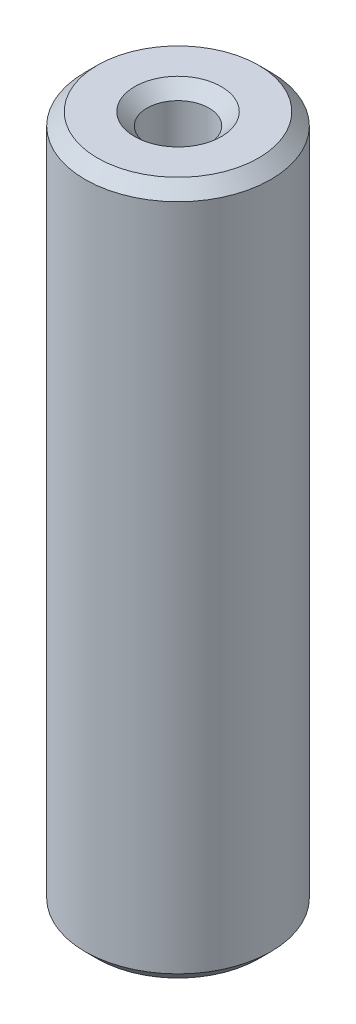
from build123d import *

# Parameters (mm, degrees)
ESQUISSE1_R      = 7.5
ESQUISSE1_R_2    = 2.5
EXTRUSION1_DEPTH = 56
CHANFREIN1_SIZE  = 1


with BuildPart() as part:
    # Esquisse1 → Extrusion1 (new body)
    with BuildSketch(Plane(origin=(0, 0, 0), x_dir=(1, 0, 0), z_dir=(0, 1, 0))):
        Circle(ESQUISSE1_R)
        Circle(ESQUISSE1_R_2, mode=Mode.SUBTRACT)
    extrude(amount=EXTRUSION1_DEPTH)

    # Chanfrein1
    chanfrein1_edges = [part.edges().sort_by_distance(p)[0] for p in [
        (-7.5, 0, 0),
        (-7.5, 56, 0),
        (-2.5, 0, 0),
        (-2.5, 56, 0),
    ]]
    chamfer(chanfrein1_edges, length=CHANFREIN1_SIZE)


solid = part.part
